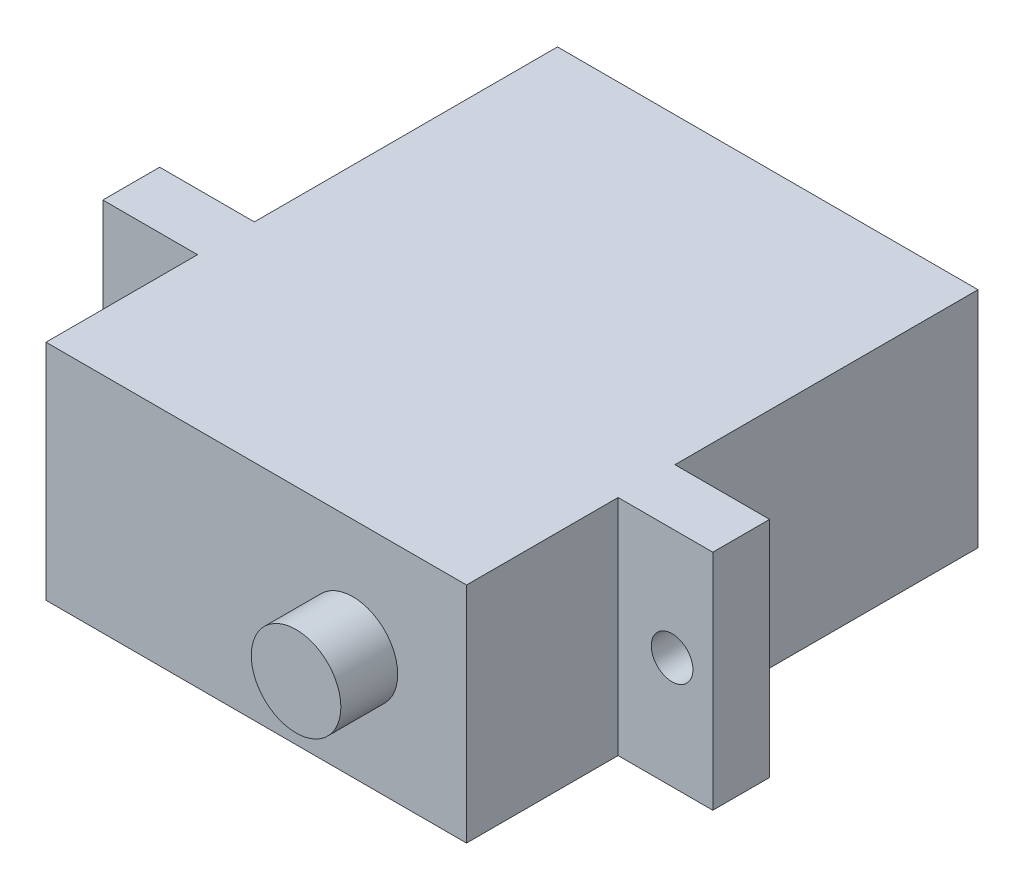
from build123d import *

# Parameters (mm, degrees)
SKETCH1_W           = 32.2
SKETCH1_H           = 11.8
BOSS_EXTRUDE1_DEPTH = 27
SKETCH2_R           = 2.365
BOSS_EXTRUDE2_DEPTH = 3
SKETCH4_W           = 16
SKETCH4_H           = 11.8
CUT_EXTRUDE1_DEPTH  = 5
SKETCH5_W           = 16
SKETCH5_H           = 11.8
CUT_EXTRUDE2_DEPTH  = 5
SKETCH6_W           = 8
SKETCH6_H           = 11.8
CUT_EXTRUDE3_DEPTH  = 5
SKETCH7_W           = 8
SKETCH7_H           = 11.8
CUT_EXTRUDE4_DEPTH  = 5
CUT_EXTRUDE5_REACH  = 21
SKETCH8_R           = 1.1


with BuildPart() as part:
    # Sketch1 → Boss-Extrude1 (new body)
    with BuildSketch(Plane.XY):
        with Locations((0, 5.9)):
            Rectangle(SKETCH1_W, SKETCH1_H)
    extrude(amount=-BOSS_EXTRUDE1_DEPTH)

    # Sketch2 → Boss-Extrude2 (add)
    with BuildSketch(Plane.XY):
        with Locations((5.1, 5.9)):
            Circle(SKETCH2_R)
    extrude(amount=BOSS_EXTRUDE2_DEPTH)

    # Sketch4 → Cut-Extrude1 (cut)
    with BuildSketch(Plane(origin=(16.1, 0, 0), x_dir=(0, 0, -1), z_dir=(1, 0, 0))):
        with Locations((19, 5.9)):
            Rectangle(SKETCH4_W, SKETCH4_H)
    extrude(amount=-CUT_EXTRUDE1_DEPTH, mode=Mode.SUBTRACT)

    # Sketch5 → Cut-Extrude2 (cut)
    with BuildSketch(Plane.ZY.offset(16.1)):
        with Locations((-19, 5.9)):
            Rectangle(SKETCH5_W, SKETCH5_H)
    extrude(amount=-CUT_EXTRUDE2_DEPTH, mode=Mode.SUBTRACT)

    # Sketch6 → Cut-Extrude3 (cut)
    with BuildSketch(Plane.ZY.offset(16.1)):
        with Locations((-4, 5.9)):
            Rectangle(SKETCH6_W, SKETCH6_H)
    extrude(amount=-CUT_EXTRUDE3_DEPTH, mode=Mode.SUBTRACT)

    # Sketch7 → Cut-Extrude4 (cut)
    with BuildSketch(Plane(origin=(16.1, 0, 0), x_dir=(0, 0, -1), z_dir=(1, 0, 0))):
        with Locations((4, 5.9)):
            Rectangle(SKETCH7_W, SKETCH7_H)
    extrude(amount=-CUT_EXTRUDE4_DEPTH, mode=Mode.SUBTRACT)

    # Sketch8 → Cut-Extrude5 (cut, up to next)
    with BuildSketch(Plane.XY.offset(-8), mode=Mode.PRIVATE) as cut_extrude5_sk1:
        with Locations((13.95, 5.9)):
            Circle(SKETCH8_R)
    cut_extrude5_tool1 = extrude(cut_extrude5_sk1.sketch, amount=-CUT_EXTRUDE5_REACH, mode=Mode.PRIVATE) & part.part
    add(cut_extrude5_tool1.solids().sort_by_distance((13.95, 5.9, -8))[0], mode=Mode.SUBTRACT)
    # Sketch8 → Cut-Extrude5 (cut, up to next)
    with BuildSketch(Plane.XY.offset(-8), mode=Mode.PRIVATE) as cut_extrude5_sk2:
        with Locations((-13.95, 5.9)):
            Circle(SKETCH8_R)
    cut_extrude5_tool2 = extrude(cut_extrude5_sk2.sketch, amount=-CUT_EXTRUDE5_REACH, mode=Mode.PRIVATE) & part.part
    add(cut_extrude5_tool2.solids().sort_by_distance((-13.95, 5.9, -8))[0], mode=Mode.SUBTRACT)


solid = part.part
